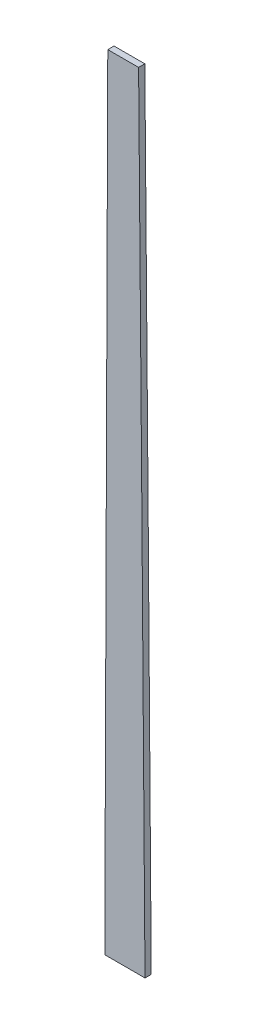
from build123d import *

# Parameters (mm, degrees)
BOSS_EXTRUDE1_DEPTH = 3.175


with BuildPart() as part:
    # Sketch2 → Boss-Extrude1 (new body)
    with BuildSketch(Plane.XY):
        with BuildLine():
            Line((-6.874706056, 0), (13.621314527, 0))
            add(Edge.make_bspline(
                [(13.621314527, 0), (12.637433669, 133.332819396), (11.568646221, 266.665030355), (10.359737829, 399.996)],
                knots=[0, 0, 0, 0, 1, 1, 1, 1], degree=3))
            Line((10.359737829, 399.996), (-5.335381197, 399.996))
            add(Edge.make_bspline(
                [(-5.335381197, 399.996), (-5.642171357, 333.330206894), (-5.915556323, 266.664264513), (-6.421942857, 133.332229763), (-6.655213864, 66.666137266), (-6.874706056, 0)],
                knots=[0, 0, 0, 0, 0.5, 0.5, 1, 1, 1, 1], degree=3))
        make_face()
    extrude(amount=BOSS_EXTRUDE1_DEPTH)


solid = part.part
